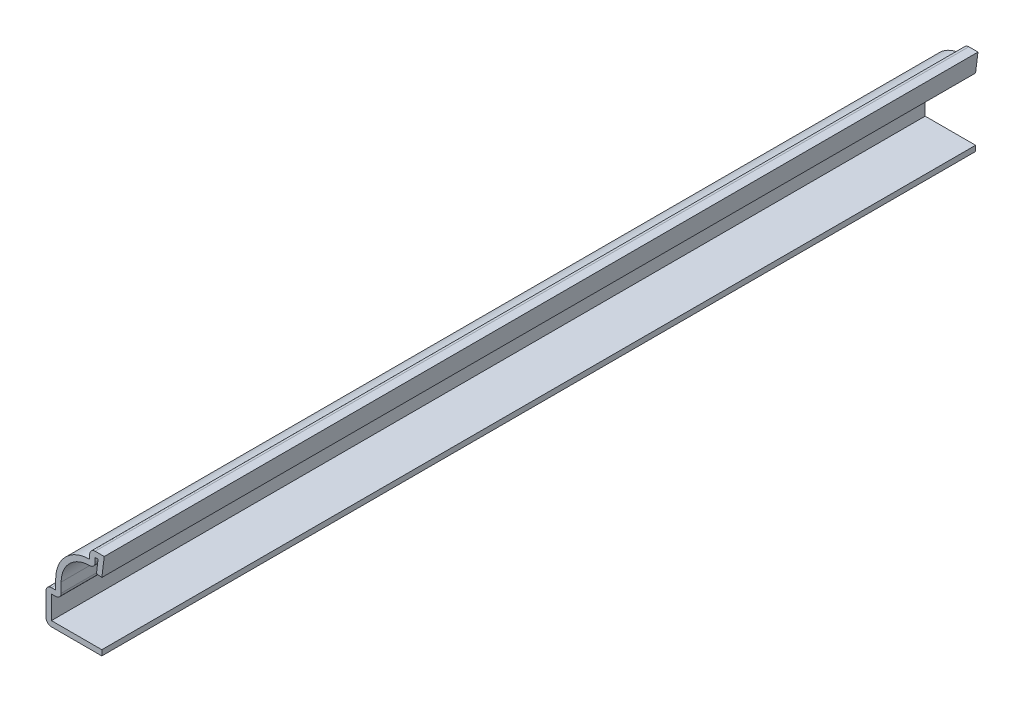
from build123d import *

# Parameters (mm, degrees)
EXTRUDE_THIN1_DEPTH = 142.875
FILLET1_R           = 0.889


with BuildPart() as part:
    # Sketch1 → Extrude-Thin1 (new body)
    with BuildSketch(Plane.XY):
        with BuildLine():
            Line((-0.396875, 0), (-9.525, 0))
            Line((-9.525, 0), (-9.525, 5.55625))
            Line((-9.525, 5.55625), (-7.9375, 5.55625))
            Line((-7.9375, 5.55625), (-7.9375, 7.14375))
            ThreePointArc((-7.9375, 7.14375), (-6.310112053, 11.072612053), (-2.38125, 12.7))
            Line((-2.38125, 12.7), (-2.38125, 14.2875))
            Line((-2.38125, 14.2875), (0, 14.2875))
            Line((0, 14.2875), (-0.396875, 11.1125))
            Line((-0.396875, 11.1125), (-1.279010032, 11.222766879))
            Line((-1.279010032, 11.222766879), (-1.007043392, 13.3985))
            Line((-1.007043392, 13.3985), (-1.49225, 13.3985))
            Line((-1.49225, 13.3985), (-1.49225, 11.725551126))
            ThreePointArc((-1.49225, 11.725551126), (-5.350596503, 10.744611551), (-7.0485, 7.14375))
            Line((-7.0485, 7.14375), (-7.0485, 4.66725))
            Line((-7.0485, 4.66725), (-8.636, 4.66725))
            Line((-8.636, 4.66725), (-8.636, 0.889))
            Line((-8.636, 0.889), (-0.396875, 0.889))
            Line((-0.396875, 0.889), (-0.396875, 0))
        make_face()
    extrude(amount=-EXTRUDE_THIN1_DEPTH)

    # Fillet1
    fillet1_edges = [part.edges().sort_by_distance(p)[0] for p in [
        (-1.49225, 11.725551126, -71.4375),
        (-7.0485, 4.66725, -71.4375),
        (-9.525, 0, -71.4375),
        (-9.525, 5.55625, -71.4375),
        (-2.38125, 14.2875, -71.4375),
    ]]
    fillet(fillet1_edges, radius=FILLET1_R)


solid = part.part
